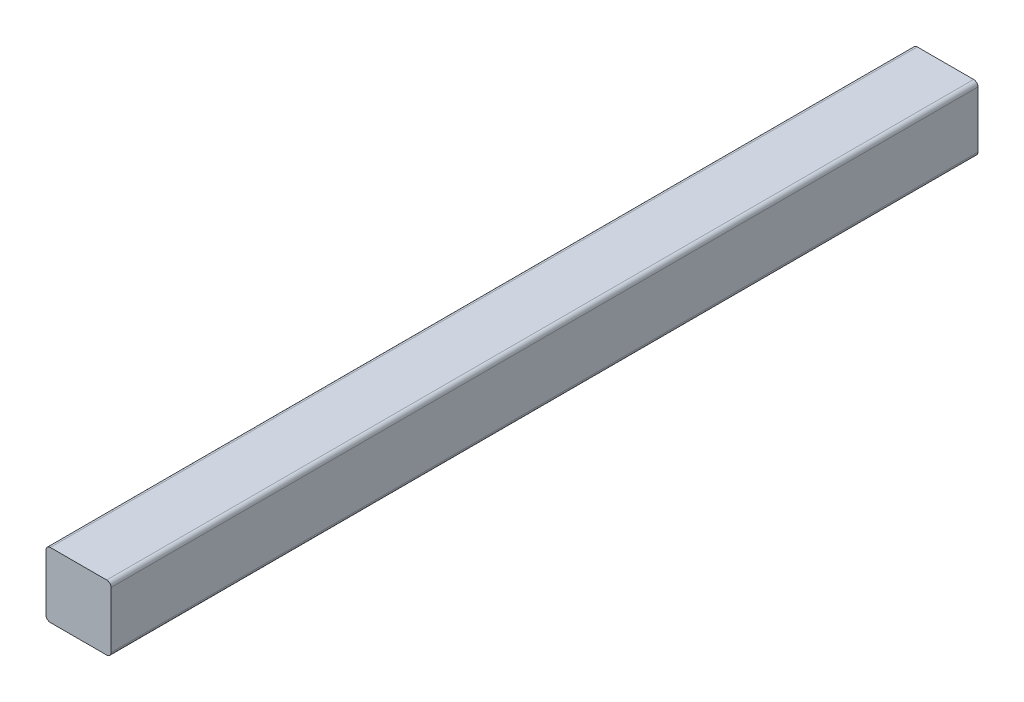
from build123d import *

# Parameters (mm, degrees)
BOSS_EXTRUDE1_DEPTH = 400


with BuildPart() as part:
    # Sketch3 → Boss-Extrude1 (new body)
    with BuildSketch(Plane.XY):
        with BuildLine():
            Line((2, 0), (28, 0))
            ThreePointArc((28, 0), (29.414213562, 0.585786438), (30, 2))
            Line((30, 2), (30, 28))
            ThreePointArc((30, 28), (29.414213562, 29.414213562), (28, 30))
            Line((28, 30), (2, 30))
            ThreePointArc((2, 30), (0.585786438, 29.414213562), (0, 28))
            Line((0, 28), (0, 2))
            ThreePointArc((0, 2), (0.585786438, 0.585786438), (2, 0))
        make_face()
    extrude(amount=BOSS_EXTRUDE1_DEPTH)


solid = part.part
